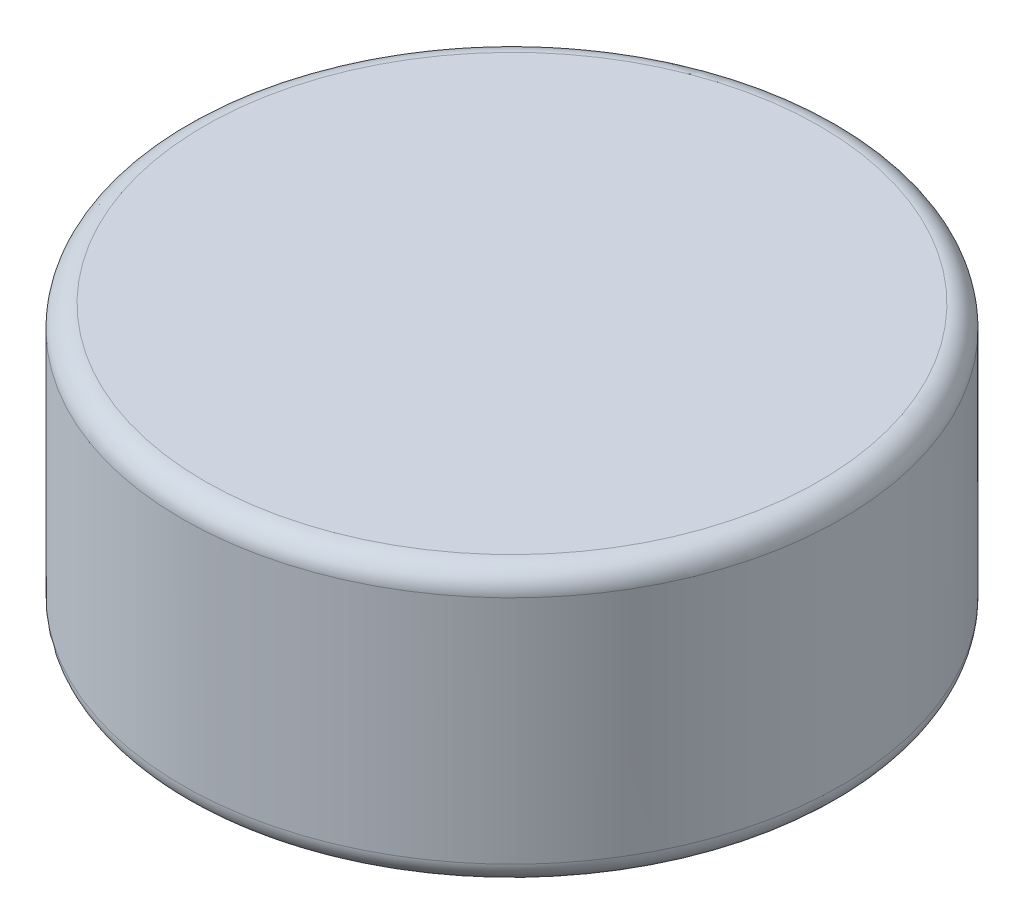
from build123d import *

# Parameters (mm, degrees)
SKETCH1_W = 3
SKETCH1_H = 2.5
FILLET1_R = 0.2


with BuildPart() as part:
    # Sketch1 → Revolve1 (revolve)
    with BuildSketch(Plane.XY):
        with Locations((1.5, 1.25)):
            Rectangle(SKETCH1_W, SKETCH1_H)
    revolve(axis=Axis((0, 0, 0), (0, 1, 0)))

    # Fillet1
    fillet1_edges = [part.edges().sort_by_distance(p)[0] for p in [
        (-3, 0, 0),
        (-3, 2.5, 0),
    ]]
    fillet(fillet1_edges, radius=FILLET1_R)


solid = part.part
